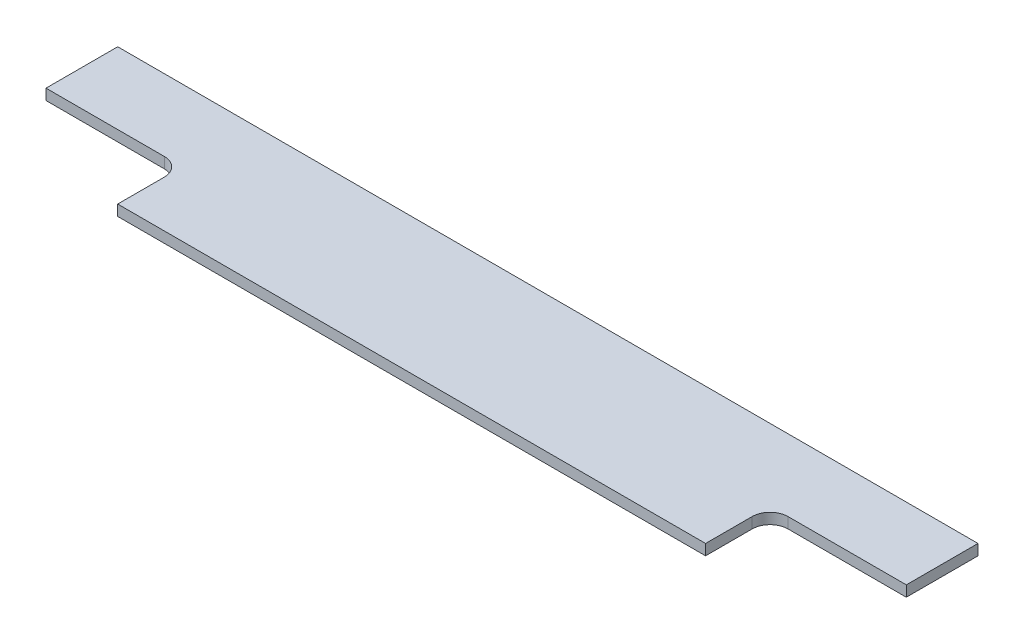
from build123d import *

# Parameters (mm, degrees)
SKETCH1_W           = 240
SKETCH1_H           = 38
BOSS_EXTRUDE1_DEPTH = 3
SKETCH2_W           = 38
SKETCH2_H           = 18
CUT_EXTRUDE1_DEPTH  = 3
FILLET1_R           = 5


with BuildPart() as part:
    # Sketch1 → Boss-Extrude1 (new body)
    with BuildSketch(Plane(origin=(0, 0, 0), x_dir=(1, 0, 0), z_dir=(0, 1, 0))):
        Rectangle(SKETCH1_W, SKETCH1_H)
    extrude(amount=BOSS_EXTRUDE1_DEPTH)

    # Sketch2 → Cut-Extrude1 (cut)
    with BuildSketch(Plane(origin=(0, 3, 0), x_dir=(1, 0, 0), z_dir=(0, 1, 0))):
        with Locations((-101, -10)):
            Rectangle(SKETCH2_W, SKETCH2_H)
        with Locations((101, -10)):
            Rectangle(SKETCH2_W, SKETCH2_H)
    extrude(amount=-CUT_EXTRUDE1_DEPTH, mode=Mode.SUBTRACT)

    # Fillet1
    fillet1_edges = [part.edges().sort_by_distance(p)[0] for p in [
        (-82, 1.5, 1),
        (82, 1.5, 1),
    ]]
    fillet(fillet1_edges, radius=FILLET1_R)


solid = part.part
